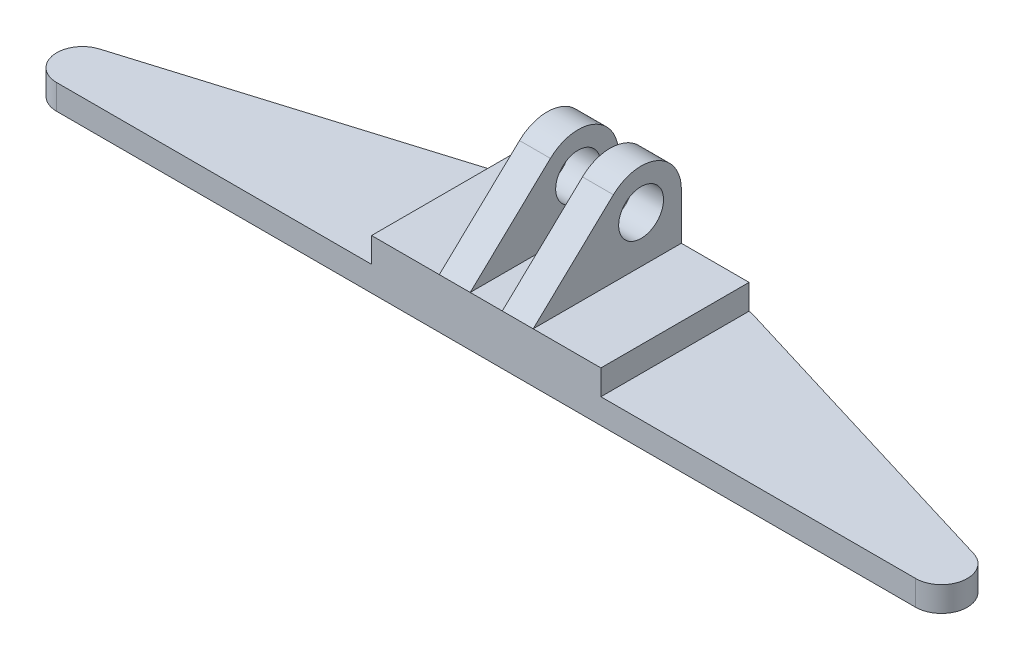
from build123d import *

# Parameters (mm, degrees)
BOSS_EXTRUDE1_DEPTH = 6.9215
FILLET1_R           = 12.7
SKETCH2_W           = 63.5635
SKETCH2_H           = 41.073046068
BOSS_EXTRUDE2_DEPTH = 6.9215
SKETCH3_R           = 6.223
BOSS_EXTRUDE4_DEPTH = 44.7929
SKETCH3_2_R         = 6.223
CUT_EXTRUDE1_DEPTH  = 18.7706
SKETCH4_W           = 8.89
SKETCH4_H           = 24.13
CUT_EXTRUDE2_DEPTH  = 42.2115


with BuildPart() as part:
    # Sketch1 → Boss-Extrude1 (new body)
    with BuildSketch(Plane(origin=(0, 0, 0), x_dir=(1, 0, 0), z_dir=(0, 1, 0))):
        with BuildLine():
            Line((5.071738793, 14.002525941), (94.4245, 41.2115))
            Line((94.4245, 41.2115), (157.988, 41.2115))
            Line((157.988, 41.2115), (247.340761207, 14.002525941))
            ThreePointArc((247.340761207, 14.002525941), (252.334481209, 6.102605506), (245.25605, 0))
            Line((245.25605, 0), (7.15645, 0))
            ThreePointArc((7.15645, 0), (0.078018791, 6.102605506), (5.071738793, 14.002525941))
        make_face()
    extrude(amount=BOSS_EXTRUDE1_DEPTH)

    # Fillet1
    fillet1_edges = [part.edges().sort_by_distance(p)[0] for p in [
        (94.4245, 3.46075, -41.2115),
        (157.988, 3.46075, -41.2115),
    ]]
    fillet(fillet1_edges, radius=FILLET1_R)

    # Sketch2 → Boss-Extrude2 (add)
    with BuildSketch(Plane(origin=(0, 6.9215, 0), x_dir=(1, 0, 0), z_dir=(0, 1, 0))):
        with Locations((126.226863171, 20.536523034)):
            Rectangle(SKETCH2_W, SKETCH2_H)
    extrude(amount=BOSS_EXTRUDE2_DEPTH)

    # Sketch3 → Boss-Extrude4 (add)
    with BuildSketch(Plane.ZY.offset(-94.445113171)):
        with BuildLine():
            Line((-41.073046068, 26.8097), (-41.073046068, 13.843))
            Line((-41.073046068, 13.843), (0, 13.843))
            Line((0, 13.843), (-22.230594652, 34.912162614))
            ThreePointArc((-22.230594652, 34.912162614), (-34.319655131, 37.065038558), (-41.073046068, 26.8097))
        make_face()
        with Locations((-29.909746068, 26.8097)):
            Circle(SKETCH3_R, mode=Mode.SUBTRACT)
    extrude(amount=-BOSS_EXTRUDE4_DEPTH)

    # Sketch3_2 → Cut-Extrude1 (cut)
    with BuildSketch(Plane.ZY.offset(-94.445113171)):
        with BuildLine():
            Line((-41.073046068, 26.8097), (-41.073046068, 13.843))
            Line((-41.073046068, 13.843), (0, 13.843))
            Line((0, 13.843), (-22.230594652, 34.912162614))
            ThreePointArc((-22.230594652, 34.912162614), (-34.319655131, 37.065038558), (-41.073046068, 26.8097))
        make_face()
        with Locations((-29.909746068, 26.8097)):
            Circle(SKETCH3_2_R, mode=Mode.SUBTRACT)
    extrude(amount=-CUT_EXTRUDE1_DEPTH, mode=Mode.SUBTRACT)

    # Sketch4 → Cut-Extrude2 (cut, through all)
    with BuildSketch(Plane.XY):
        with Locations((126.226863171, 25.908)):
            Rectangle(SKETCH4_W, SKETCH4_H)
    extrude(amount=-CUT_EXTRUDE2_DEPTH, mode=Mode.SUBTRACT)


solid = part.part
